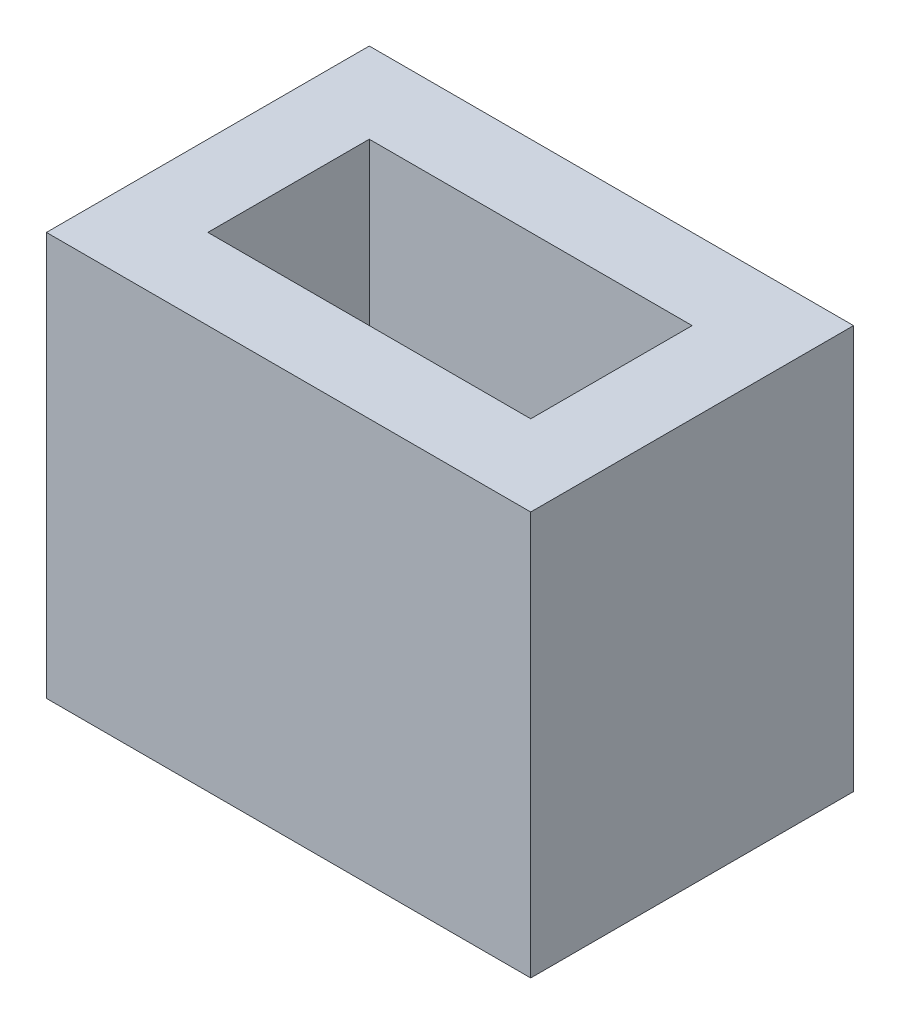
from build123d import *

# Parameters (mm, degrees)
SKETCH_1_W      = 12
SKETCH_1_H      = 8
SKETCH_1_W_2    = 8
SKETCH_1_H_2    = 4
EXTRUDE_1_DEPTH = 10


with BuildPart() as part:
    # 草图1 → 凸台-拉伸1 (new body)
    with BuildSketch(Plane(origin=(0, 0, 0), x_dir=(1, 0, 0), z_dir=(0, 1, 0))):
        Rectangle(SKETCH_1_W, SKETCH_1_H)
        Rectangle(SKETCH_1_W_2, SKETCH_1_H_2, mode=Mode.SUBTRACT)
    extrude(amount=EXTRUDE_1_DEPTH)


solid = part.part
